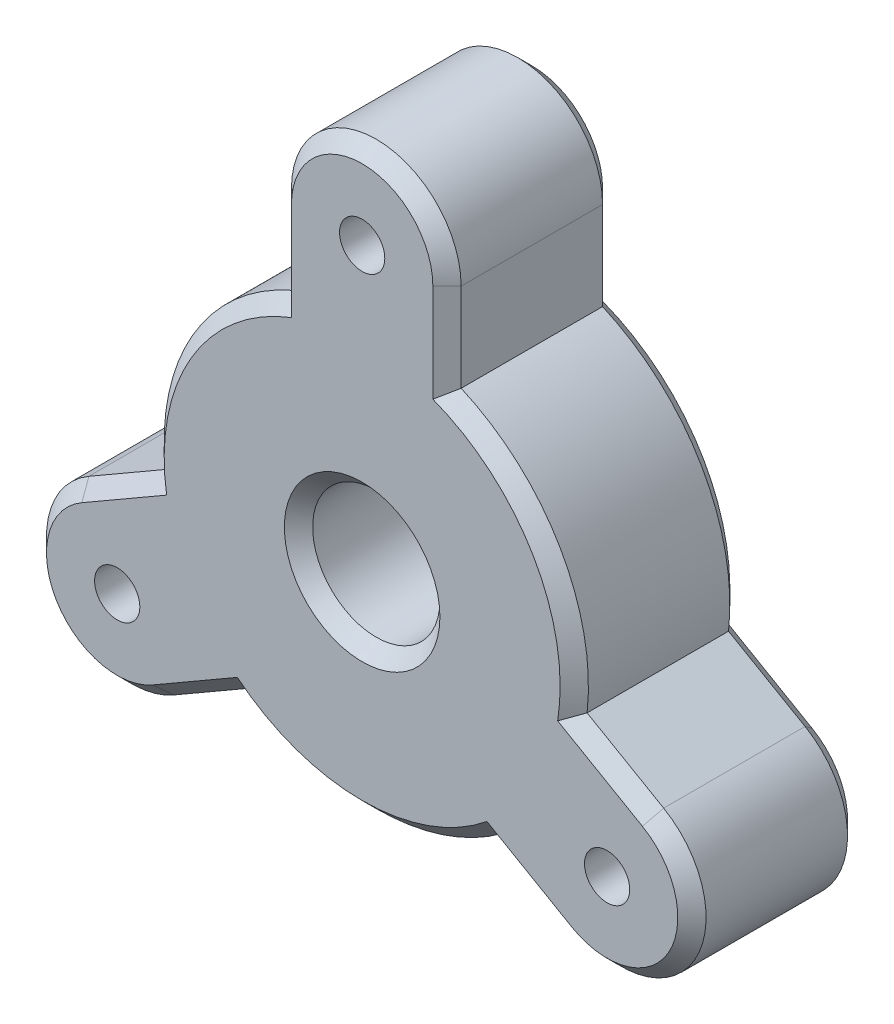
from build123d import *

# Parameters (mm, degrees)
SKETCH1_R                       = 15
BOSS_EXTRUDE1_DEPTH             = 6
BOSS_EXTRUDE2_REACH             = 8
BOSS_EXTRUDE2_DIRECTION_2_REACH = 8
SKETCH3_R                       = 4.5
CUT_EXTRUDE1_DEPTH              = 7
CUT_EXTRUDE1_DEPTH_BACK         = 7
CHAMFER1_SIZE                   = 1
SKETCH4_R                       = 1.6
CUT_EXTRUDE2_DEPTH              = 7
CUT_EXTRUDE2_DEPTH_BACK         = 7


with BuildPart() as part:
    # Sketch1 → Boss-Extrude1 (new body, symmetric)
    with BuildSketch(Plane.XY):
        Circle(SKETCH1_R)
    extrude(amount=BOSS_EXTRUDE1_DEPTH, both=True)

    # Boss-Extrude2: up to this face of the body (flat: up to its plane)
    boss_extrude2_end = Plane(part.part.faces().sort_by_distance((0, 0, 6))[0])
    # Sketch2 → Boss-Extrude2 (add, up to the picked face)
    with BuildSketch(Plane.XY, mode=Mode.PRIVATE) as boss_extrude2_sk1:
        with BuildLine():
            Line((-6, 20), (-6, 13.747727085))
            Line((-6, 13.747727085), (6, 13.747727085))
            Line((6, 13.747727085), (6, 20))
            ThreePointArc((6, 20), (0, 26), (-6, 20))
        make_face()
    boss_extrude2_tool1 = split(extrude(boss_extrude2_sk1.sketch, amount=BOSS_EXTRUDE2_REACH, mode=Mode.PRIVATE), bisect_by=boss_extrude2_end, keep=Keep.BOTH, mode=Mode.PRIVATE)
    add(boss_extrude2_tool1.solids().sort_by_distance((0, 19.311838, 0))[0])
    # Sketch2 → Boss-Extrude2 (add, up to the picked face)
    with BuildSketch(Plane.XY, mode=Mode.PRIVATE) as boss_extrude2_sk2:
        with BuildLine():
            Line((20.320508076, -4.803847577), (14.9058809, -1.67771112))
            Line((14.9058809, -1.67771112), (8.9058809, -12.070015965))
            Line((8.9058809, -12.070015965), (14.320508076, -15.196152423))
            ThreePointArc((14.320508076, -15.196152423), (22.516660498, -13), (20.320508076, -4.803847577))
        make_face()
    boss_extrude2_tool2 = split(extrude(boss_extrude2_sk2.sketch, amount=BOSS_EXTRUDE2_REACH, mode=Mode.PRIVATE), bisect_by=boss_extrude2_end, keep=Keep.BOTH, mode=Mode.PRIVATE)
    add(boss_extrude2_tool2.solids().sort_by_distance((16.724543, -9.655919, 0))[0])
    # Sketch2 → Boss-Extrude2 (add, up to the picked face)
    with BuildSketch(Plane.XY, mode=Mode.PRIVATE) as boss_extrude2_sk3:
        with BuildLine():
            Line((-14.320508076, -15.196152423), (-8.9058809, -12.070015965))
            Line((-8.9058809, -12.070015965), (-14.9058809, -1.67771112))
            Line((-14.9058809, -1.67771112), (-20.320508076, -4.803847577))
            ThreePointArc((-20.320508076, -4.803847577), (-22.516660498, -13), (-14.320508076, -15.196152423))
        make_face()
    boss_extrude2_tool3 = split(extrude(boss_extrude2_sk3.sketch, amount=BOSS_EXTRUDE2_REACH, mode=Mode.PRIVATE), bisect_by=boss_extrude2_end, keep=Keep.BOTH, mode=Mode.PRIVATE)
    add(boss_extrude2_tool3.solids().sort_by_distance((-16.724543, -9.655919, 0))[0])

    # Boss-Extrude2 direction 2: up to this face of the body (flat: up to its plane)
    boss_extrude2_direction_2_end = Plane(part.part.faces().sort_by_distance((0, 0, -6))[0])
    # Sketch2 → Boss-Extrude2 direction 2 (add, up to the picked face)
    with BuildSketch(Plane.XY, mode=Mode.PRIVATE) as boss_extrude2_direction_2_sk1:
        with BuildLine():
            Line((-6, 20), (-6, 13.747727085))
            Line((-6, 13.747727085), (6, 13.747727085))
            Line((6, 13.747727085), (6, 20))
            ThreePointArc((6, 20), (0, 26), (-6, 20))
        make_face()
    boss_extrude2_direction_2_tool1 = split(extrude(boss_extrude2_direction_2_sk1.sketch, amount=-BOSS_EXTRUDE2_DIRECTION_2_REACH, mode=Mode.PRIVATE), bisect_by=boss_extrude2_direction_2_end, keep=Keep.BOTH, mode=Mode.PRIVATE)
    add(boss_extrude2_direction_2_tool1.solids().sort_by_distance((0, 19.311838, 0))[0])
    # Sketch2 → Boss-Extrude2 direction 2 (add, up to the picked face)
    with BuildSketch(Plane.XY, mode=Mode.PRIVATE) as boss_extrude2_direction_2_sk2:
        with BuildLine():
            Line((20.320508076, -4.803847577), (14.9058809, -1.67771112))
            Line((14.9058809, -1.67771112), (8.9058809, -12.070015965))
            Line((8.9058809, -12.070015965), (14.320508076, -15.196152423))
            ThreePointArc((14.320508076, -15.196152423), (22.516660498, -13), (20.320508076, -4.803847577))
        make_face()
    boss_extrude2_direction_2_tool2 = split(extrude(boss_extrude2_direction_2_sk2.sketch, amount=-BOSS_EXTRUDE2_DIRECTION_2_REACH, mode=Mode.PRIVATE), bisect_by=boss_extrude2_direction_2_end, keep=Keep.BOTH, mode=Mode.PRIVATE)
    add(boss_extrude2_direction_2_tool2.solids().sort_by_distance((16.724543, -9.655919, 0))[0])
    # Sketch2 → Boss-Extrude2 direction 2 (add, up to the picked face)
    with BuildSketch(Plane.XY, mode=Mode.PRIVATE) as boss_extrude2_direction_2_sk3:
        with BuildLine():
            Line((-14.320508076, -15.196152423), (-8.9058809, -12.070015965))
            Line((-8.9058809, -12.070015965), (-14.9058809, -1.67771112))
            Line((-14.9058809, -1.67771112), (-20.320508076, -4.803847577))
            ThreePointArc((-20.320508076, -4.803847577), (-22.516660498, -13), (-14.320508076, -15.196152423))
        make_face()
    boss_extrude2_direction_2_tool3 = split(extrude(boss_extrude2_direction_2_sk3.sketch, amount=-BOSS_EXTRUDE2_DIRECTION_2_REACH, mode=Mode.PRIVATE), bisect_by=boss_extrude2_direction_2_end, keep=Keep.BOTH, mode=Mode.PRIVATE)
    add(boss_extrude2_direction_2_tool3.solids().sort_by_distance((-16.724543, -9.655919, 0))[0])

    # Sketch3 → Cut-Extrude1 (cut, two sides)
    with BuildSketch(Plane.XY) as cut_extrude1_sk:
        Circle(SKETCH3_R)
    extrude(amount=CUT_EXTRUDE1_DEPTH, mode=Mode.SUBTRACT)
    extrude(cut_extrude1_sk.sketch, amount=-CUT_EXTRUDE1_DEPTH_BACK, mode=Mode.SUBTRACT)

    # Chamfer1
    chamfer1_edges = [part.edges().sort_by_distance(p)[0] for p in [
        (12.990381057, 7.5, -6),
        (12.990381057, 7.5, 6),
        (11.613194488, -13.633084194, 6),
        (22.516660498, -13, 6),
        (17.613194488, -3.240779349, 6),
        (11.613194488, -13.633084194, -6),
        (17.613194488, -3.240779349, -6),
        (22.516660498, -13, -6),
        (0, -15, -6),
        (0, -15, 6),
        (-17.613194488, -3.240779349, 6),
        (-22.516660498, -13, 6),
        (-11.613194488, -13.633084194, 6),
        (-17.613194488, -3.240779349, -6),
        (-11.613194488, -13.633084194, -6),
        (-22.516660498, -13, -6),
        (-4.5, 0, -6),
        (-4.5, 0, 6),
        (-12.990381057, 7.5, -6),
        (-12.990381057, 7.5, 6),
        (6, 16.873863542, 6),
        (0, 26, 6),
        (-6, 16.873863542, 6),
        (6, 16.873863542, -6),
        (-6, 16.873863542, -6),
        (0, 26, -6),
    ]]
    chamfer(chamfer1_edges, length=CHAMFER1_SIZE)

    # Sketch4 → Cut-Extrude2 (cut, two sides)
    with BuildSketch(Plane.XY) as cut_extrude2_sk:
        with Locations((0, 20)):
            Circle(SKETCH4_R)
        with Locations((17.320508076, -10)):
            Circle(SKETCH4_R)
        with Locations((-17.320508076, -10)):
            Circle(SKETCH4_R)
    extrude(amount=CUT_EXTRUDE2_DEPTH, mode=Mode.SUBTRACT)
    extrude(cut_extrude2_sk.sketch, amount=-CUT_EXTRUDE2_DEPTH_BACK, mode=Mode.SUBTRACT)


solid = part.part
